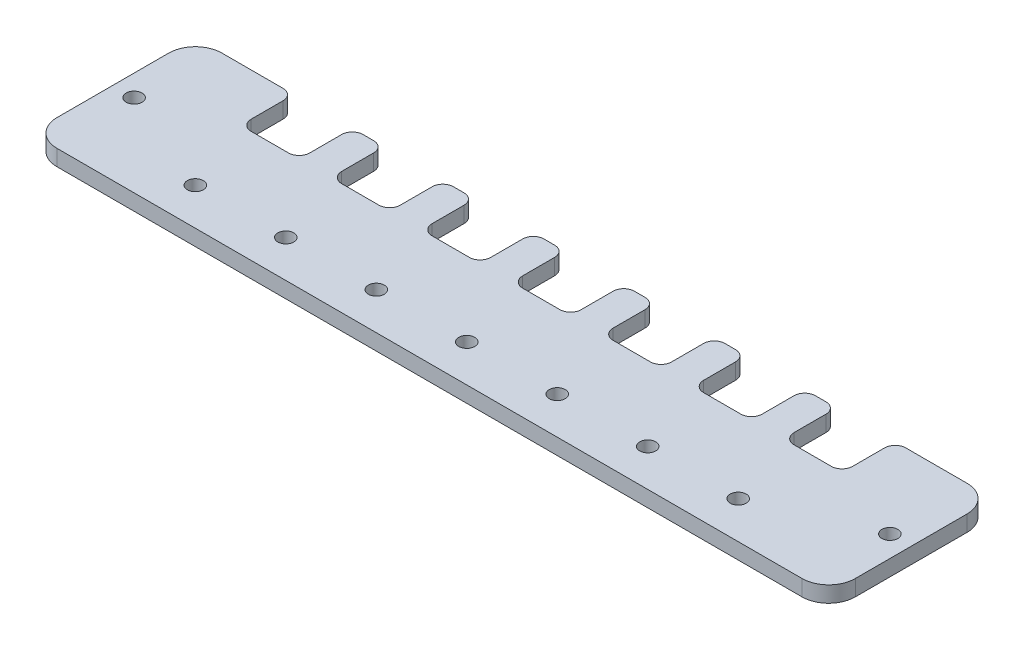
from build123d import *

# Parameters (mm, degrees)
SKETCH1_R           = 1.5
BOSS_EXTRUDE1_DEPTH = 3


with BuildPart() as part:
    # Sketch1 → Boss-Extrude1 (new body)
    with BuildSketch(Plane(origin=(0, 0, 0), x_dir=(1, 0, 0), z_dir=(0, 1, 0))):
        with BuildLine():
            Line((70, 15.5), (58.5, 15.5))
            ThreePointArc((58.5, 15.5), (57.085786438, 14.914213562), (56.5, 13.5))
            Line((56.5, 13.5), (56.5, 7.5))
            ThreePointArc((56.5, 7.5), (55.914213562, 6.085786438), (54.5, 5.5))
            Line((54.5, 5.5), (47.5, 5.5))
            ThreePointArc((47.5, 5.5), (46.085786438, 6.085786438), (45.5, 7.5))
            Line((45.5, 7.5), (45.5, 13.5))
            ThreePointArc((45.5, 13.5), (44.914213562, 14.914213562), (43.5, 15.5))
            Line((43.5, 15.5), (41.5, 15.5))
            ThreePointArc((41.5, 15.5), (40.085786438, 14.914213562), (39.5, 13.5))
            Line((39.5, 13.5), (39.5, 7.5))
            ThreePointArc((39.5, 7.5), (38.914213562, 6.085786438), (37.5, 5.5))
            Line((37.5, 5.5), (30.5, 5.5))
            ThreePointArc((30.5, 5.5), (29.085786438, 6.085786438), (28.5, 7.5))
            Line((28.5, 7.5), (28.5, 13.5))
            ThreePointArc((28.5, 13.5), (27.914213562, 14.914213562), (26.5, 15.5))
            Line((26.5, 15.5), (24.5, 15.5))
            ThreePointArc((24.5, 15.5), (23.085786438, 14.914213562), (22.5, 13.5))
            Line((22.5, 13.5), (22.5, 7.5))
            ThreePointArc((22.5, 7.5), (21.914213562, 6.085786438), (20.5, 5.5))
            Line((20.5, 5.5), (13.5, 5.5))
            ThreePointArc((13.5, 5.5), (12.085786438, 6.085786438), (11.5, 7.5))
            Line((11.5, 7.5), (11.5, 13.5))
            ThreePointArc((11.5, 13.5), (10.914213562, 14.914213562), (9.5, 15.5))
            Line((9.5, 15.5), (7.5, 15.5))
            ThreePointArc((7.5, 15.5), (6.085786438, 14.914213562), (5.5, 13.5))
            Line((5.5, 13.5), (5.5, 7.5))
            ThreePointArc((5.5, 7.5), (4.914213562, 6.085786438), (3.5, 5.5))
            Line((3.5, 5.5), (-3.5, 5.5))
            ThreePointArc((-3.5, 5.5), (-4.914213562, 6.085786438), (-5.5, 7.5))
            Line((-5.5, 7.5), (-5.5, 13.5))
            ThreePointArc((-5.5, 13.5), (-6.085786438, 14.914213562), (-7.5, 15.5))
            Line((-7.5, 15.5), (-9.5, 15.5))
            ThreePointArc((-9.5, 15.5), (-10.914213562, 14.914213562), (-11.5, 13.5))
            Line((-11.5, 13.5), (-11.5, 7.5))
            ThreePointArc((-11.5, 7.5), (-12.085786438, 6.085786438), (-13.5, 5.5))
            Line((-13.5, 5.5), (-20.5, 5.5))
            ThreePointArc((-20.5, 5.5), (-21.914213562, 6.085786438), (-22.5, 7.5))
            Line((-22.5, 7.5), (-22.5, 13.5))
            ThreePointArc((-22.5, 13.5), (-23.085786438, 14.914213562), (-24.5, 15.5))
            Line((-24.5, 15.5), (-26.5, 15.5))
            ThreePointArc((-26.5, 15.5), (-27.914213562, 14.914213562), (-28.5, 13.5))
            Line((-28.5, 13.5), (-28.5, 7.5))
            ThreePointArc((-28.5, 7.5), (-29.085786438, 6.085786438), (-30.5, 5.5))
            Line((-30.5, 5.5), (-37.5, 5.5))
            ThreePointArc((-37.5, 5.5), (-38.914213562, 6.085786438), (-39.5, 7.5))
            Line((-39.5, 7.5), (-39.5, 13.5))
            ThreePointArc((-39.5, 13.5), (-40.085786438, 14.914213562), (-41.5, 15.5))
            Line((-41.5, 15.5), (-43.5, 15.5))
            ThreePointArc((-43.5, 15.5), (-44.914213562, 14.914213562), (-45.5, 13.5))
            Line((-45.5, 13.5), (-45.5, 7.5))
            ThreePointArc((-45.5, 7.5), (-46.085786438, 6.085786438), (-47.5, 5.5))
            Line((-47.5, 5.5), (-54.5, 5.5))
            ThreePointArc((-54.5, 5.5), (-55.914213562, 6.085786438), (-56.5, 7.5))
            Line((-56.5, 7.5), (-56.5, 13.5))
            ThreePointArc((-56.5, 13.5), (-57.085786438, 14.914213562), (-58.5, 15.5))
            Line((-58.5, 15.5), (-70, 15.5))
            ThreePointArc((-70, 15.5), (-73.535533906, 14.035533906), (-75, 10.5))
            Line((-75, 10.5), (-75, -10.5))
            ThreePointArc((-75, -10.5), (-73.535533906, -14.035533906), (-70, -15.5))
            Line((-70, -15.5), (70, -15.5))
            ThreePointArc((70, -15.5), (73.535533906, -14.035533906), (75, -10.5))
            Line((75, -10.5), (75, 10.5))
            ThreePointArc((75, 10.5), (73.535533906, 14.035533906), (70, 15.5))
        make_face()
        with Locations((71, 0)):
            Circle(SKETCH1_R, mode=Mode.SUBTRACT)
        with Locations((-51, -8.5)):
            Circle(SKETCH1_R, mode=Mode.SUBTRACT)
        with Locations((-34, -8.5)):
            Circle(SKETCH1_R, mode=Mode.SUBTRACT)
        with Locations((-17, -8.5)):
            Circle(SKETCH1_R, mode=Mode.SUBTRACT)
        with Locations((0, -8.5)):
            Circle(SKETCH1_R, mode=Mode.SUBTRACT)
        with Locations((17, -8.5)):
            Circle(SKETCH1_R, mode=Mode.SUBTRACT)
        with Locations((34, -8.5)):
            Circle(SKETCH1_R, mode=Mode.SUBTRACT)
        with Locations((51, -8.5)):
            Circle(SKETCH1_R, mode=Mode.SUBTRACT)
        with Locations((-71, 0)):
            Circle(SKETCH1_R, mode=Mode.SUBTRACT)
    extrude(amount=BOSS_EXTRUDE1_DEPTH)


solid = part.part
